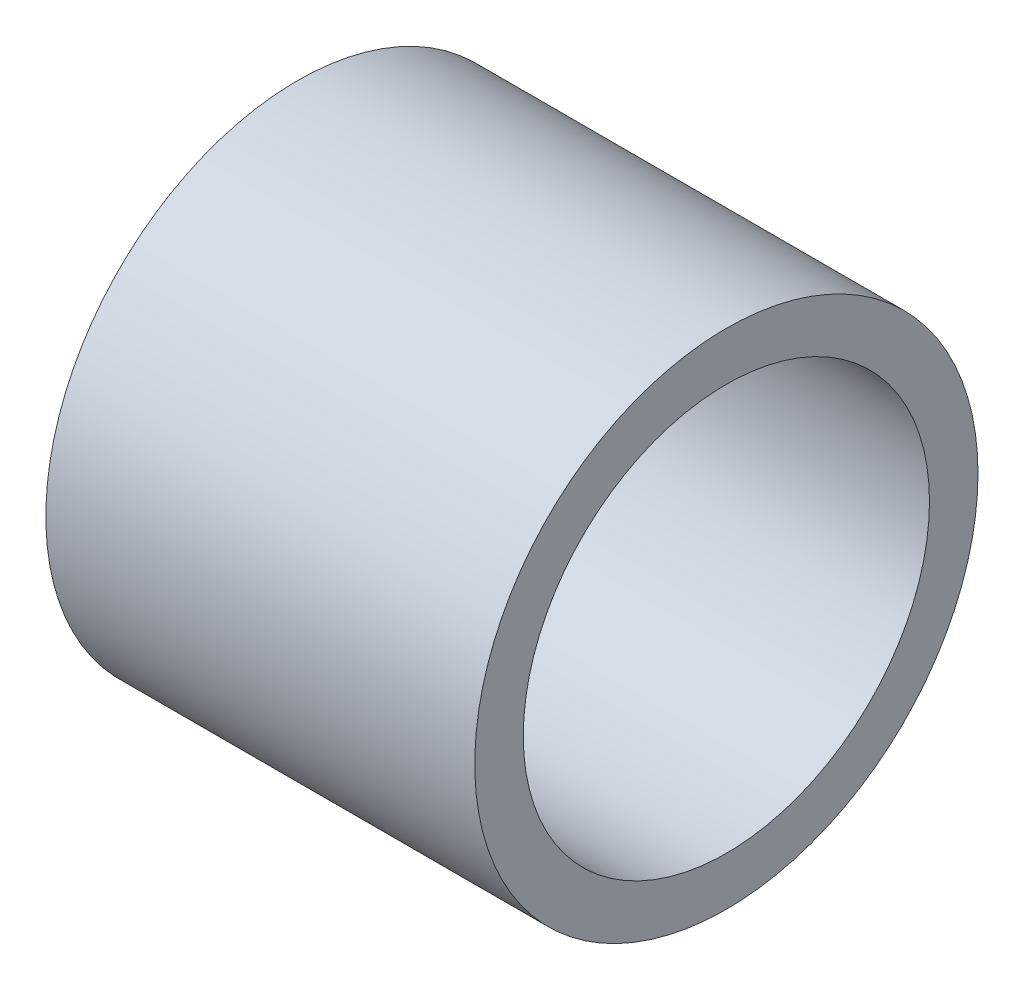
from build123d import *

# Parameters (mm, degrees)
SKETCH1_R           = 8.382
SKETCH1_R_2         = 6.765925
BOSS_EXTRUDE1_DEPTH = 14.2875


with BuildPart() as part:
    # Sketch1 → Boss-Extrude1 (new body)
    with BuildSketch(Plane(origin=(0, 0, 0), x_dir=(0, 0, -1), z_dir=(1, 0, 0))):
        Circle(SKETCH1_R)
        Circle(SKETCH1_R_2, mode=Mode.SUBTRACT)
    extrude(amount=BOSS_EXTRUDE1_DEPTH)


solid = part.part
